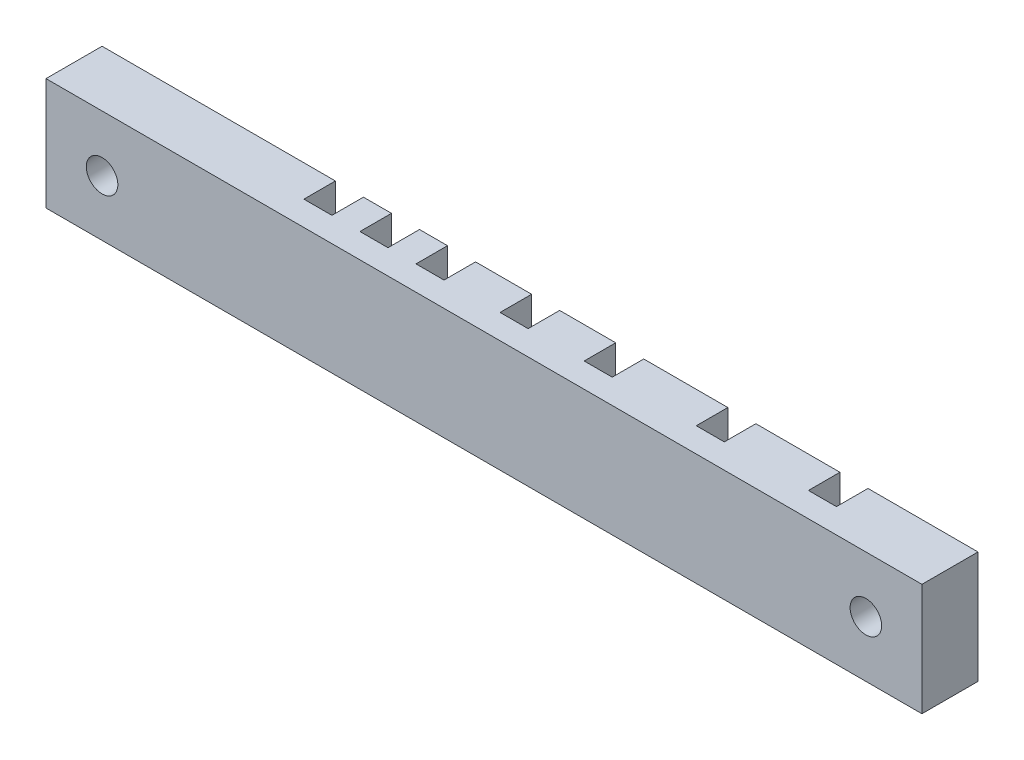
from build123d import *

# Parameters (mm, degrees)
SKETCH2_W           = 125
SKETCH2_H           = 16
BOSS_EXTRUDE1_DEPTH = 8
SKETCH3_W           = 4
SKETCH3_H           = 6.863597229
SKETCH3_H_2         = 10.419332053
CUT_EXTRUDE1_DEPTH  = 17
SKETCH4_R           = 4
CUT_EXTRUDE2_DEPTH  = 4.4
SKETCH5_R           = 2.25
CUT_EXTRUDE3_DEPTH  = 4.6


with BuildPart() as part:
    # Sketch2 → Boss-Extrude1 (new body)
    with BuildSketch(Plane.XY):
        with Locations((3.707075963, 6.242976067)):
            Rectangle(SKETCH2_W, SKETCH2_H)
    extrude(amount=BOSS_EXTRUDE1_DEPTH)

    # Sketch3 → Cut-Extrude1 (cut, through all)
    with BuildSketch(Plane(origin=(0, 14.242976067, 0), x_dir=(1, 0, 0), z_dir=(0, 1, 0))):
        with Locations((48.507075963, -1.068201385)):
            Rectangle(SKETCH3_W, SKETCH3_H)
        with Locations((32.507075963, 0.709666027)):
            Rectangle(SKETCH3_W, SKETCH3_H_2)
        with Locations((16.507075963, 0.709666027)):
            Rectangle(SKETCH3_W, SKETCH3_H_2)
        with Locations((4.507075963, 0.709666027)):
            Rectangle(SKETCH3_W, SKETCH3_H_2)
        with Locations((-7.492924037, 0.709666027)):
            Rectangle(SKETCH3_W, SKETCH3_H_2)
        with Locations((-15.492924037, 0.709666027)):
            Rectangle(SKETCH3_W, SKETCH3_H_2)
        with Locations((-23.492924037, 0.709666027)):
            Rectangle(SKETCH3_W, SKETCH3_H_2)
    extrude(amount=-CUT_EXTRUDE1_DEPTH, mode=Mode.SUBTRACT)

    # Sketch4 → Cut-Extrude2 (cut)
    with BuildSketch(Plane(origin=(0, 0, 0), x_dir=(-1, 0, 0), z_dir=(0, 0, -1))):
        with Locations((50.792924037, 6.242976067)):
            Circle(SKETCH4_R)
        with Locations((-58.207075963, 6.242976067)):
            Circle(SKETCH4_R)
    extrude(amount=-CUT_EXTRUDE2_DEPTH, mode=Mode.SUBTRACT)

    # Sketch5 → Cut-Extrude3 (cut, through all)
    with BuildSketch(Plane(origin=(0, 0, 4.4), x_dir=(-1, 0, 0), z_dir=(0, 0, -1))):
        with Locations((50.792924037, 6.242976067)):
            Circle(SKETCH5_R)
        with Locations((-58.207075963, 6.242976067)):
            Circle(SKETCH5_R)
    extrude(amount=-CUT_EXTRUDE3_DEPTH, mode=Mode.SUBTRACT)


solid = part.part
